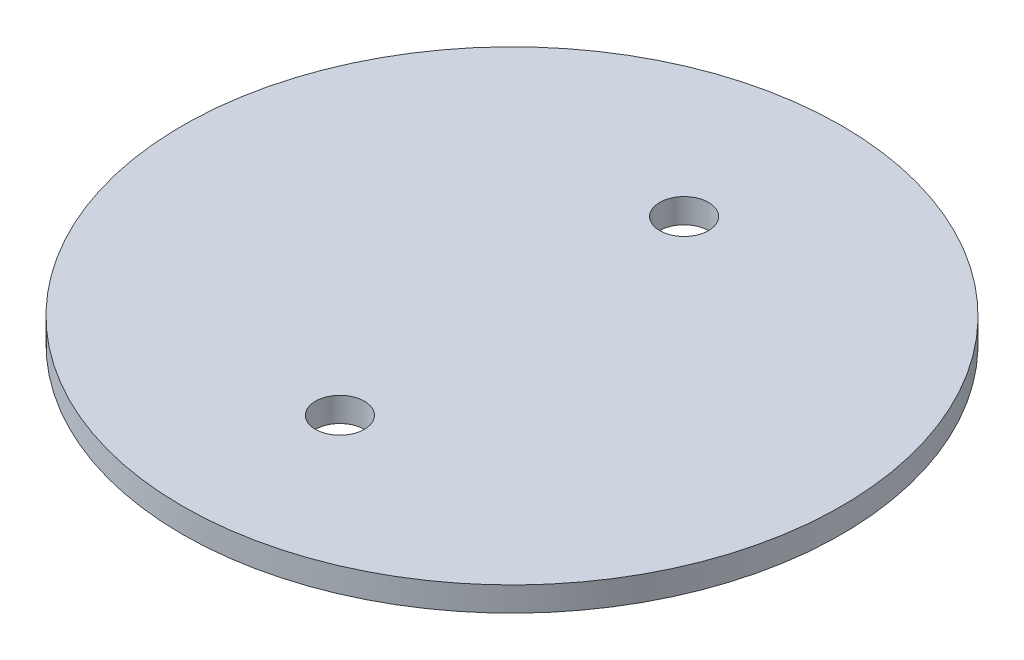
from build123d import *

# Parameters (mm, degrees)
SKETCH1_R           = 42.799
SKETCH1_R_2         = 3.175
BOSS_EXTRUDE1_DEPTH = 3.175


with BuildPart() as part:
    # Sketch1 → Boss-Extrude1 (new body)
    with BuildSketch(Plane(origin=(0, 0, 0), x_dir=(1, 0, 0), z_dir=(0, 1, 0))):
        Circle(SKETCH1_R)
        with Locations((0, -22.352)):
            Circle(SKETCH1_R_2, mode=Mode.SUBTRACT)
        with Locations((0, 22.352)):
            Circle(SKETCH1_R_2, mode=Mode.SUBTRACT)
    extrude(amount=BOSS_EXTRUDE1_DEPTH)


solid = part.part
